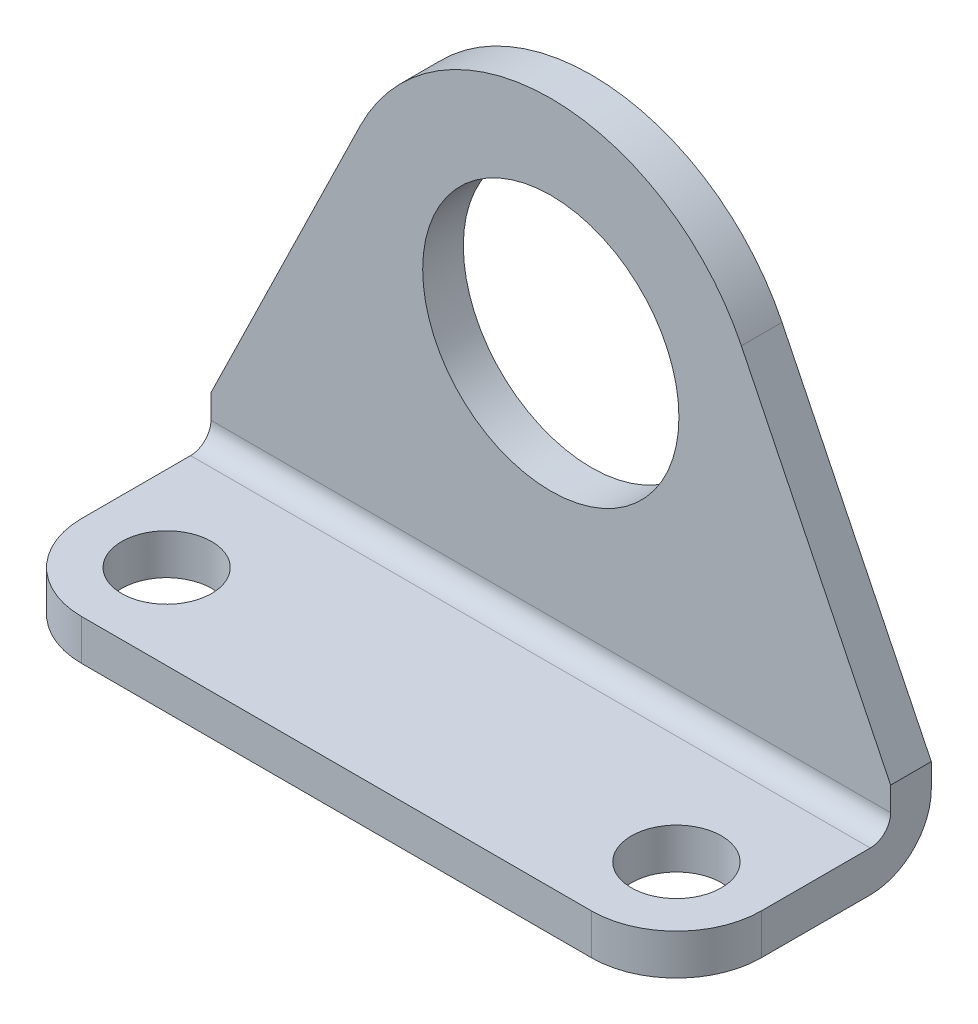
from build123d import *

# Parameters (mm, degrees)
BOSS_EXTRUDE1_DEPTH = 25.4
SKETCH2_W           = 35.56
SKETCH2_H           = 32.385
CUT_EXTRUDE1_DEPTH  = 2.27838
SKETCH3_R           = 4.7879
CUT_EXTRUDE2_DEPTH  = 2.27838
SKETCH4_R           = 1.68275
CUT_EXTRUDE3_DEPTH  = 2.27838
SKETCH5_R           = 1.68275
CUT_EXTRUDE4_DEPTH  = 2.27838
CUT_EXTRUDE5_DEPTH  = 2.27838
CUT_EXTRUDE6_DEPTH  = 2.27838


with BuildPart() as part:
    # Sketch1 → Boss-Extrude1 (new body)
    with BuildSketch(Plane(origin=(0, 0, 0), x_dir=(0, 0, -1), z_dir=(1, 0, 0))):
        with BuildLine():
            Line((-9.525, 1.51892), (-9.525, 0))
            Line((-9.525, 0), (-2.28092, 0))
            ThreePointArc((-2.28092, 0), (-0.668066001, 0.668066001), (0, 2.28092))
            Line((0, 2.28092), (0, 22.86))
            Line((0, 22.86), (-1.51892, 22.86))
            Line((-1.51892, 22.86), (-1.51892, 2.28092))
            ThreePointArc((-1.51892, 2.28092), (-1.742104633, 1.742104633), (-2.28092, 1.51892))
            Line((-2.28092, 1.51892), (-9.525, 1.51892))
        make_face()
    extrude(amount=BOSS_EXTRUDE1_DEPTH)

    # Sketch2 → Cut-Extrude1 (cut)
    with BuildSketch(Plane.XY):
        with Locations((12.7, 14.2875)):
            Rectangle(SKETCH2_W, SKETCH2_H)
        with BuildLine():
            Line((-1.550018352, 0), (26.950018352, 0))
            Line((26.950018352, 0), (19.821465766, 14.601862247))
            ThreePointArc((19.821465766, 14.601862247), (12.7, 19.05), (5.578534234, 14.601862247))
            Line((5.578534234, 14.601862247), (-1.550018352, 0))
        make_face(mode=Mode.SUBTRACT)
    extrude(amount=CUT_EXTRUDE1_DEPTH, mode=Mode.SUBTRACT)

    # Sketch3 → Cut-Extrude2 (cut)
    with BuildSketch(Plane.XY):
        with Locations((12.7, 11.1252)):
            Circle(SKETCH3_R)
    extrude(amount=CUT_EXTRUDE2_DEPTH, mode=Mode.SUBTRACT)

    # Sketch4 → Cut-Extrude3 (cut)
    with BuildSketch(Plane(origin=(0, 0, 0), x_dir=(1, 0, 0), z_dir=(0, 1, 0))):
        with Locations((3.175, -6.35)):
            Circle(SKETCH4_R)
    extrude(amount=CUT_EXTRUDE3_DEPTH, mode=Mode.SUBTRACT)

    # Sketch5 → Cut-Extrude4 (cut)
    with BuildSketch(Plane(origin=(0, 0, 0), x_dir=(1, 0, 0), z_dir=(0, 1, 0))):
        with Locations((22.225, -6.35)):
            Circle(SKETCH5_R)
    extrude(amount=CUT_EXTRUDE4_DEPTH, mode=Mode.SUBTRACT)

    # Sketch6 → Cut-Extrude5 (cut)
    with BuildSketch(Plane(origin=(0, 0, 0), x_dir=(1, 0, 0), z_dir=(0, 1, 0))):
        with BuildLine():
            Line((-12.7, -12.7), (3.175, -12.7))
            Line((3.175, -12.7), (3.175, -9.525))
            ThreePointArc((3.175, -9.525), (0.92993597, -8.59506403), (0, -6.35))
            Line((0, -6.35), (-12.7, -6.35))
            Line((-12.7, -6.35), (-12.7, -12.7))
        make_face()
    extrude(amount=CUT_EXTRUDE5_DEPTH, mode=Mode.SUBTRACT)

    # Sketch7 → Cut-Extrude6 (cut)
    with BuildSketch(Plane(origin=(0, 0, 0), x_dir=(1, 0, 0), z_dir=(0, 1, 0))):
        with BuildLine():
            Line((22.225, -9.525), (22.225, -12.7))
            Line((22.225, -12.7), (38.1, -12.7))
            Line((38.1, -12.7), (38.1, -6.35))
            Line((38.1, -6.35), (25.4, -6.35))
            ThreePointArc((25.4, -6.35), (24.47006403, -8.59506403), (22.225, -9.525))
        make_face()
    extrude(amount=CUT_EXTRUDE6_DEPTH, mode=Mode.SUBTRACT)


solid = part.part
